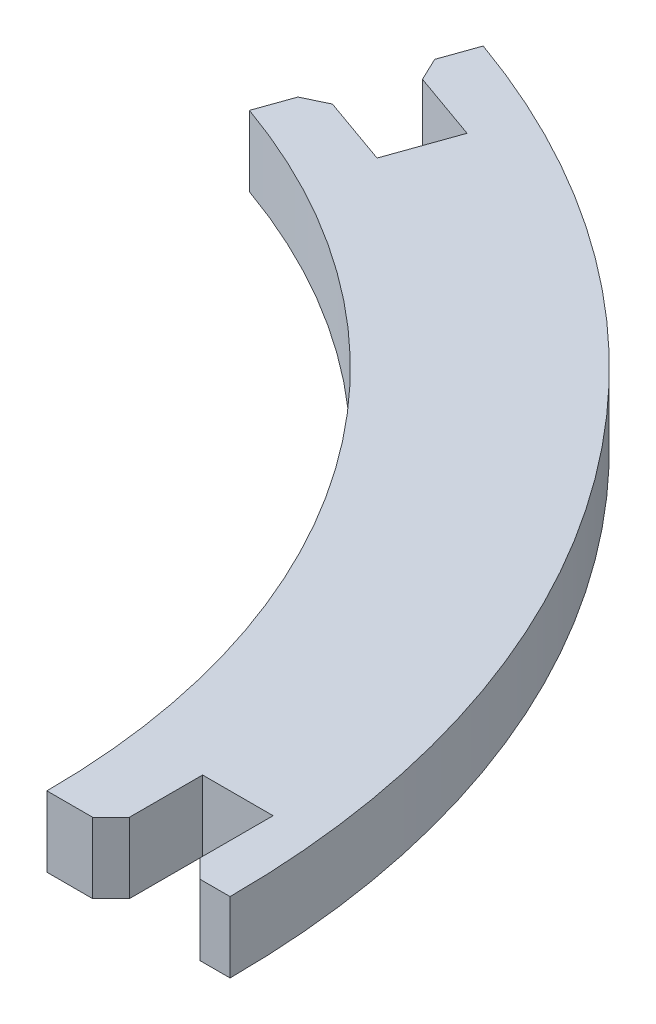
from build123d import *

# Parameters (mm, degrees)
BOSS_EXTRUDE1_DEPTH = 3.85
CHAMFER1_SIZE       = 1


with BuildPart() as part:
    # Sketch1 → Boss-Extrude1 (new body)
    with BuildSketch(Plane(origin=(0, 0, 0), x_dir=(1, 0, 0), z_dir=(0, 1, 0))):
        with BuildLine():
            Line((-35.18752665, 46.966281406), (-36.213982742, 44.067658821))
            Line((-36.213982742, 44.067658821), (-31.500775287, 42.398624525))
            Line((-31.500775287, 42.398624525), (-32.785931695, 38.769454784))
            Line((-32.785931695, 38.769454784), (-37.49913915, 40.438489081))
            Line((-37.49913915, 40.438489081), (-38.525595242, 37.539866495))
            ThreePointArc((-38.525595242, 37.539866495), (-19.212207405, 22.920014453), (-11.877869612, -0.165793148))
            Line((-11.877869612, -0.165793148), (-8.376973606, -0.165793148))
            Line((-8.376973606, -0.165793148), (-8.376973606, 4.834206852))
            Line((-8.376973606, 4.834206852), (-4.526973606, 4.834206852))
            Line((-4.526973606, 4.834206852), (-4.526973606, -0.165793148))
            Line((-4.526973606, -0.165793148), (-1.877869612, -0.165793148))
            ThreePointArc((-1.877869612, -0.165793148), (-11.045791854, 28.691466354), (-35.18752665, 46.966281406))
        make_face()
    extrude(amount=BOSS_EXTRUDE1_DEPTH)

    # Chamfer1
    chamfer1_edges = [part.edges().sort_by_distance(p)[0] for p in [
        (-4.526973606, 1.925, 0.165793148),
        (-8.376973606, 1.925, 0.165793148),
        (-37.49913915, 1.925, -40.438489081),
        (-36.213982742, 1.925, -44.067658821),
    ]]
    chamfer(chamfer1_edges, length=CHAMFER1_SIZE)


solid = part.part
